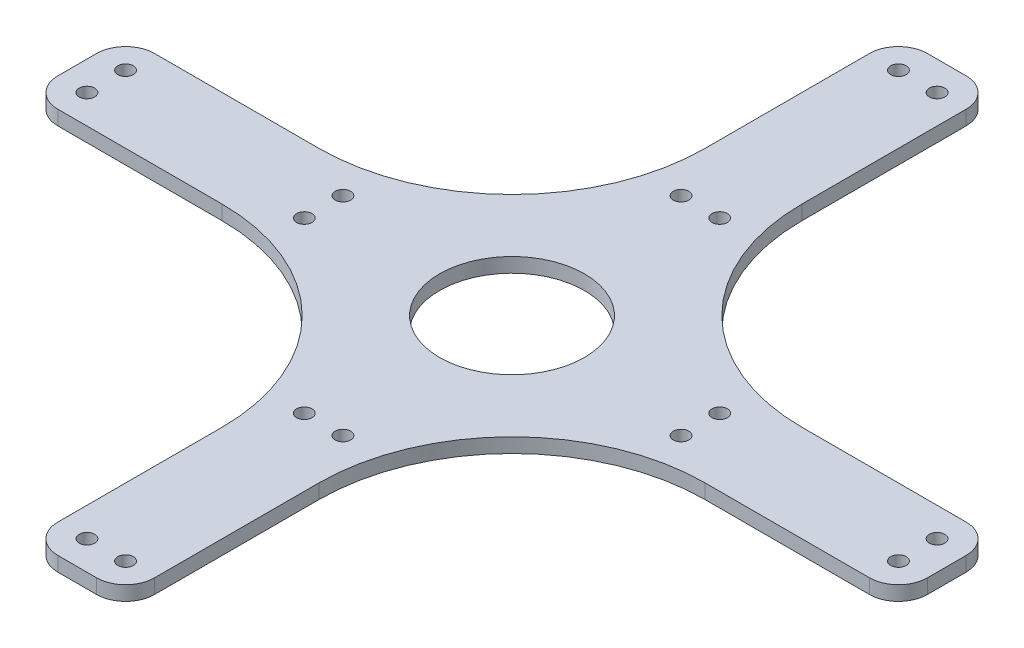
from build123d import *

# Parameters (mm, degrees)
BOSS_EXTRUDE1_DEPTH      = 1.5
M3_CLEARANCE_HOLE1_D     = 3.2
M3_CLEARANCE_HOLE1_DEPTH = 3
SKETCH5_R                = 15
CUT_EXTRUDE1_DEPTH       = 1
CUT_EXTRUDE1_DEPTH_BACK  = 4


with BuildPart() as part:
    # Sketch1 → Boss-Extrude1 (new body, symmetric)
    with BuildSketch(Plane(origin=(0, 0, 0), x_dir=(1, 0, 0), z_dir=(0, 1, 0))):
        with BuildLine():
            Line((50, 10), (84, 10))
            ThreePointArc((84, 10), (88.242640687, 8.242640687), (90, 4))
            Line((90, 4), (90, -4))
            ThreePointArc((90, -4), (88.242640687, -8.242640687), (84, -10))
            Line((84, -10), (50, -10))
            ThreePointArc((50, -10), (21.715728753, -21.715728753), (10, -50))
            Line((10, -50), (10, -84))
            ThreePointArc((10, -84), (8.242640687, -88.242640687), (4, -90))
            Line((4, -90), (-4, -90))
            ThreePointArc((-4, -90), (-8.242640687, -88.242640687), (-10, -84))
            Line((-10, -84), (-10, -50))
            ThreePointArc((-10, -50), (-21.715728753, -21.715728753), (-50, -10))
            Line((-50, -10), (-84, -10))
            ThreePointArc((-84, -10), (-88.242640687, -8.242640687), (-90, -4))
            Line((-90, -4), (-90, 4))
            ThreePointArc((-90, 4), (-88.242640687, 8.242640687), (-84, 10))
            Line((-84, 10), (-50, 10))
            ThreePointArc((-50, 10), (-21.715728753, 21.715728753), (-10, 50))
            Line((-10, 50), (-10, 84))
            ThreePointArc((-10, 84), (-8.242640687, 88.242640687), (-4, 90))
            Line((-4, 90), (4, 90))
            ThreePointArc((4, 90), (8.242640687, 88.242640687), (10, 84))
            Line((10, 84), (10, 50))
            ThreePointArc((10, 50), (21.715728753, 21.715728753), (50, 10))
        make_face()
    extrude(amount=BOSS_EXTRUDE1_DEPTH, both=True)

    # M3 Clearance Hole1
    with Locations(Plane(origin=(0, 1.5, 0), x_dir=(1, 0, 0), z_dir=(0, 1, 0))):
        with Locations((-84, 4), (-84, -4), (-4, 84), (4, 84), (84, 4), (84, -4), (4, -84), (-4, -84), (-39, 4), (-39, -4), (39, 4), (39, -4), (4, -39), (-4, -39), (-4, 39), (4, 39)):
            Hole(M3_CLEARANCE_HOLE1_D / 2, depth=M3_CLEARANCE_HOLE1_DEPTH)

    # Sketch5 → Cut-Extrude1 (cut, two sides)
    with BuildSketch(Plane(origin=(0, 1.5, 0), x_dir=(1, 0, 0), z_dir=(0, 1, 0))) as cut_extrude1_sk:
        Circle(SKETCH5_R)
    extrude(amount=CUT_EXTRUDE1_DEPTH, mode=Mode.SUBTRACT)
    extrude(cut_extrude1_sk.sketch, amount=-CUT_EXTRUDE1_DEPTH_BACK, mode=Mode.SUBTRACT)


solid = part.part
